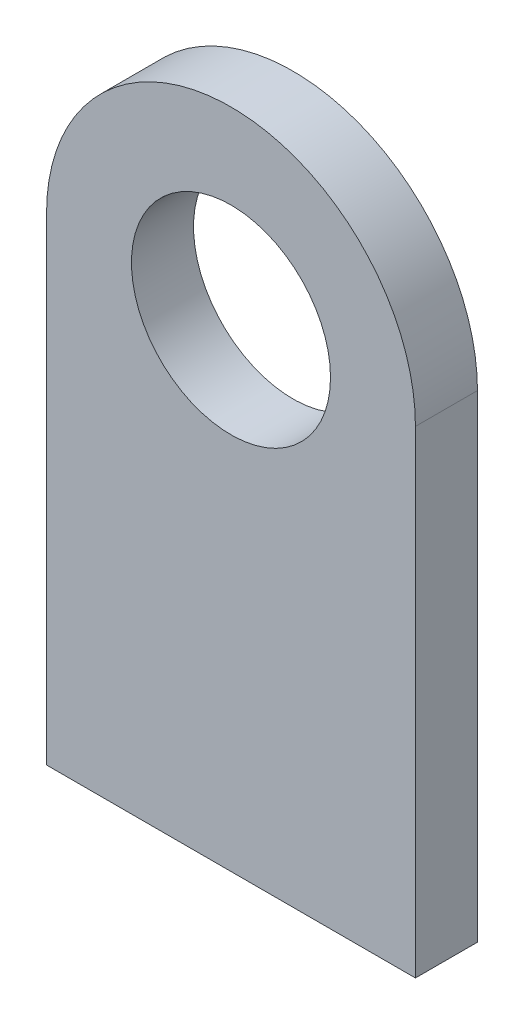
from build123d import *

# Parameters (mm, degrees)
SKETCH1_R           = 15
BOSS_EXTRUDE1_DEPTH = 9.35


with BuildPart() as part:
    # Sketch1 → Boss-Extrude1 (new body)
    with BuildSketch(Plane.XY):
        with BuildLine():
            Line((-27.8, 0), (-27.8, -72))
            Line((-27.8, -72), (27.8, -72))
            Line((27.8, -72), (27.8, 0))
            ThreePointArc((27.8, 0), (0, 27.8), (-27.8, 0))
        make_face()
        Circle(SKETCH1_R, mode=Mode.SUBTRACT)
    extrude(amount=BOSS_EXTRUDE1_DEPTH)


solid = part.part
